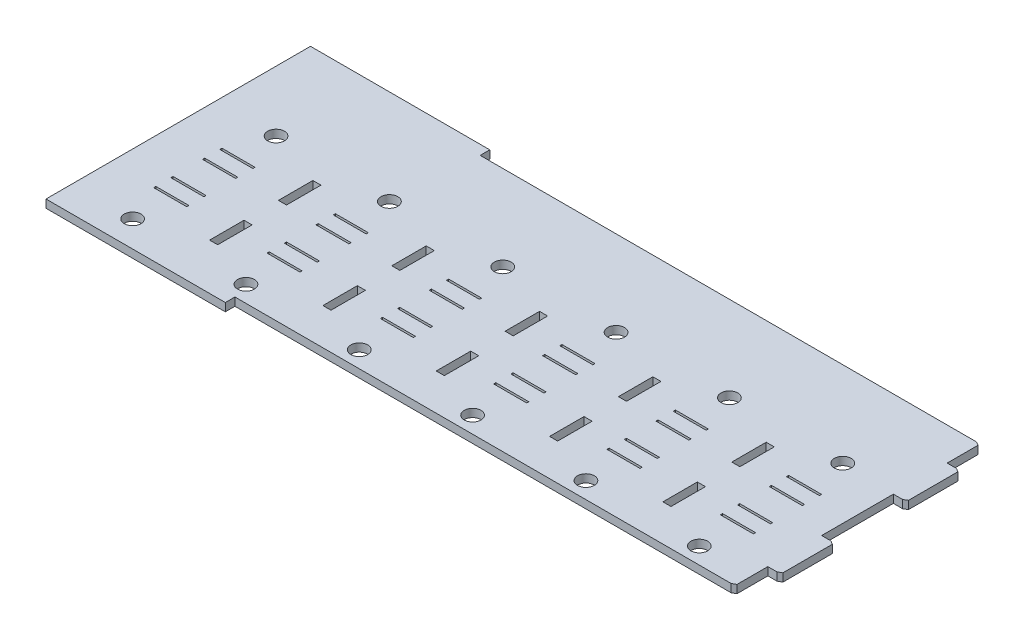
from build123d import *

# Parameters (mm, degrees)
SKETCH1_W             = 245.11
SKETCH1_H             = 93.653112922
BOSS_EXTRUDE1_DEPTH   = 2.8575
CUT_EXTRUDE1_REACH    = 4.857
SKETCH2_W             = 181.61
SKETCH2_H             = 3.399764473
CUT_EXTRUDE3_REACH    = 4.857
SKETCH4_W             = 4.572
SKETCH4_H             = 11.676791988
SKETCH4_H_2           = 25.4
CHAMFER2_SIZE         = 0.762
CHAMFER2_SIZE2        = 1.319822715
CHAMFER2_PART_2_SIZE  = 0.762
CHAMFER2_PART_2_SIZE2 = 1.319822715
CHAMFER2_PART_3_SIZE  = 0.762
CHAMFER2_PART_3_SIZE2 = 1.319822715
CHAMFER3_SIZE         = 0.762
CHAMFER3_SIZE2        = 1.319822715
CHAMFER3_PART_2_SIZE  = 0.762
CHAMFER3_PART_2_SIZE2 = 1.319822715
CHAMFER3_PART_3_SIZE  = 0.762
CHAMFER3_PART_3_SIZE2 = 1.319822715
SKETCH6_W             = 11.684
SKETCH6_H             = 0.762
CUT_EXTRUDE4_DEPTH    = 3.8575
SKETCH9_W             = 2.86258
SKETCH9_H             = 12.192
CUT_EXTRUDE5_DEPTH    = 3.8575
SKETCH11_R            = 2.975
CUT_EXTRUDE6_DEPTH    = 3.8575


with BuildPart() as part:
    # Sketch1 → Boss-Extrude1 (new body)
    with BuildSketch(Plane(origin=(0, 0, 0), x_dir=(1, 0, 0), z_dir=(0, 1, 0))):
        Rectangle(SKETCH1_W, SKETCH1_H)
    extrude(amount=BOSS_EXTRUDE1_DEPTH)

    # Sketch2 → Cut-Extrude1 (cut, up to next)
    with BuildSketch(Plane(origin=(0, 2.8575, 0), x_dir=(1, 0, 0), z_dir=(0, 1, 0)), mode=Mode.PRIVATE) as cut_extrude1_sk1:
        with Locations((31.75, 45.126674225)):
            Rectangle(SKETCH2_W, SKETCH2_H)
    cut_extrude1_tool1 = extrude(cut_extrude1_sk1.sketch, amount=-CUT_EXTRUDE1_REACH, mode=Mode.PRIVATE) & part.part
    add(cut_extrude1_tool1.solids().sort_by_distance((31.75, 2.8575, -45.126674))[0], mode=Mode.SUBTRACT)
    # Sketch2 → Cut-Extrude1 (cut, up to next)
    with BuildSketch(Plane(origin=(0, 2.8575, 0), x_dir=(1, 0, 0), z_dir=(0, 1, 0)), mode=Mode.PRIVATE) as cut_extrude1_sk2:
        with Locations((31.75, -45.126674225)):
            Rectangle(SKETCH2_W, SKETCH2_H)
    cut_extrude1_tool2 = extrude(cut_extrude1_sk2.sketch, amount=-CUT_EXTRUDE1_REACH, mode=Mode.PRIVATE) & part.part
    add(cut_extrude1_tool2.solids().sort_by_distance((31.75, 2.8575, 45.126674))[0], mode=Mode.SUBTRACT)

    # Sketch4 → Cut-Extrude3 (cut, up to next)
    with BuildSketch(Plane(origin=(0, 2.8575, 0), x_dir=(1, 0, 0), z_dir=(0, 1, 0)), mode=Mode.PRIVATE) as cut_extrude3_sk1:
        with Locations((120.269, 37.588395994)):
            Rectangle(SKETCH4_W, SKETCH4_H)
    cut_extrude3_tool1 = extrude(cut_extrude3_sk1.sketch, amount=-CUT_EXTRUDE3_REACH, mode=Mode.PRIVATE) & part.part
    add(cut_extrude3_tool1.solids().sort_by_distance((120.269, 2.8575, -37.588396))[0], mode=Mode.SUBTRACT)
    # Sketch4 → Cut-Extrude3 (cut, up to next)
    with BuildSketch(Plane(origin=(0, 2.8575, 0), x_dir=(1, 0, 0), z_dir=(0, 1, 0)), mode=Mode.PRIVATE) as cut_extrude3_sk2:
        with Locations((120.269, -37.588395994)):
            Rectangle(SKETCH4_W, SKETCH4_H)
    cut_extrude3_tool2 = extrude(cut_extrude3_sk2.sketch, amount=-CUT_EXTRUDE3_REACH, mode=Mode.PRIVATE) & part.part
    add(cut_extrude3_tool2.solids().sort_by_distance((120.269, 2.8575, 37.588396))[0], mode=Mode.SUBTRACT)
    # Sketch4 → Cut-Extrude3 (cut, up to next)
    with BuildSketch(Plane(origin=(0, 2.8575, 0), x_dir=(1, 0, 0), z_dir=(0, 1, 0)), mode=Mode.PRIVATE) as cut_extrude3_sk3:
        with Locations((120.269, 0)):
            Rectangle(SKETCH4_W, SKETCH4_H_2)
    cut_extrude3_tool3 = extrude(cut_extrude3_sk3.sketch, amount=-CUT_EXTRUDE3_REACH, mode=Mode.PRIVATE) & part.part
    add(cut_extrude3_tool3.solids().sort_by_distance((120.269, 2.8575, 0))[0], mode=Mode.SUBTRACT)

    # Chamfer2
    chamfer2_edges = [part.edges().sort_by_distance(p)[0] for p in [
        (122.555, 1.42875, 31.75),
    ]]
    chamfer2_side = [part.faces().sort_by_distance(p)[0] for p in [
        (122.555, 1.42875, 22.225),
    ]]
    chamfer(chamfer2_edges, length=CHAMFER2_SIZE, length2=CHAMFER2_SIZE2, reference=chamfer2_side[0])

    # Chamfer2 part 2
    chamfer2_part_2_edges = [part.edges().sort_by_distance(p)[0] for p in [
        (117.983, 1.42875, 43.426791988),
    ]]
    chamfer2_part_2_side = [part.faces().sort_by_distance(p)[0] for p in [
        (117.983, 1.42875, 37.588395994),
    ]]
    chamfer(chamfer2_part_2_edges, length=CHAMFER2_PART_2_SIZE, length2=CHAMFER2_PART_2_SIZE2, reference=chamfer2_part_2_side[0])

    # Chamfer2 part 3
    chamfer2_part_3_edges = [part.edges().sort_by_distance(p)[0] for p in [
        (122.555, 1.42875, -12.7),
    ]]
    chamfer2_part_3_side = [part.faces().sort_by_distance(p)[0] for p in [
        (122.555, 1.42875, -22.225),
    ]]
    chamfer(chamfer2_part_3_edges, length=CHAMFER2_PART_3_SIZE, length2=CHAMFER2_PART_3_SIZE2, reference=chamfer2_part_3_side[0])

    # Chamfer3
    chamfer3_edges = [part.edges().sort_by_distance(p)[0] for p in [
        (122.555, 1.42875, -31.75),
    ]]
    chamfer3_side = [part.faces().sort_by_distance(p)[0] for p in [
        (122.555, 1.42875, -22.606),
    ]]
    chamfer(chamfer3_edges, length=CHAMFER3_SIZE, length2=CHAMFER3_SIZE2, reference=chamfer3_side[0])

    # Chamfer3 part 2
    chamfer3_part_2_edges = [part.edges().sort_by_distance(p)[0] for p in [
        (117.983, 1.42875, -43.426791988),
    ]]
    chamfer3_part_2_side = [part.faces().sort_by_distance(p)[0] for p in [
        (117.983, 1.42875, -37.588395994),
    ]]
    chamfer(chamfer3_part_2_edges, length=CHAMFER3_PART_2_SIZE, length2=CHAMFER3_PART_2_SIZE2, reference=chamfer3_part_2_side[0])

    # Chamfer3 part 3
    chamfer3_part_3_edges = [part.edges().sort_by_distance(p)[0] for p in [
        (122.555, 1.42875, 12.7),
    ]]
    chamfer3_part_3_side = [part.faces().sort_by_distance(p)[0] for p in [
        (122.555, 1.42875, 21.844),
    ]]
    chamfer(chamfer3_part_3_edges, length=CHAMFER3_PART_3_SIZE, length2=CHAMFER3_PART_3_SIZE2, reference=chamfer3_part_3_side[0])

    # Sketch6 → Cut-Extrude4 (cut, through all)
    with BuildSketch(Plane(origin=(0, 2.8575, 0), x_dir=(1, 0, 0), z_dir=(0, 1, 0))):
        with Locations((99.533234068, -0.475391988)):
            Rectangle(SKETCH6_W, SKETCH6_H)
        with Locations((99.533234068, -6.571391988)):
            Rectangle(SKETCH6_W, SKETCH6_H)
        with Locations((99.533234068, -17.802329902)):
            Rectangle(SKETCH6_W, SKETCH6_H)
        with Locations((99.533234068, -23.898329902)):
            Rectangle(SKETCH6_W, SKETCH6_H)
        with Locations((59.401234068, -0.475391988)):
            Rectangle(SKETCH6_W, SKETCH6_H)
        with Locations((59.401234068, -6.571391988)):
            Rectangle(SKETCH6_W, SKETCH6_H)
        with Locations((59.401234068, -17.802329902)):
            Rectangle(SKETCH6_W, SKETCH6_H)
        with Locations((59.401234068, -23.898329902)):
            Rectangle(SKETCH6_W, SKETCH6_H)
        with Locations((19.269234068, -0.475391988)):
            Rectangle(SKETCH6_W, SKETCH6_H)
        with Locations((19.269234068, -6.571391988)):
            Rectangle(SKETCH6_W, SKETCH6_H)
        with Locations((19.269234068, -17.802329902)):
            Rectangle(SKETCH6_W, SKETCH6_H)
        with Locations((19.269234068, -23.898329902)):
            Rectangle(SKETCH6_W, SKETCH6_H)
        with Locations((-20.862765932, -0.475391988)):
            Rectangle(SKETCH6_W, SKETCH6_H)
        with Locations((-20.862765932, -6.571391988)):
            Rectangle(SKETCH6_W, SKETCH6_H)
        with Locations((-20.862765932, -17.802329902)):
            Rectangle(SKETCH6_W, SKETCH6_H)
        with Locations((-20.862765932, -23.898329902)):
            Rectangle(SKETCH6_W, SKETCH6_H)
        with Locations((-60.994765932, -0.475391988)):
            Rectangle(SKETCH6_W, SKETCH6_H)
        with Locations((-60.994765932, -6.571391988)):
            Rectangle(SKETCH6_W, SKETCH6_H)
        with Locations((-60.994765932, -17.802329902)):
            Rectangle(SKETCH6_W, SKETCH6_H)
        with Locations((-60.994765932, -23.898329902)):
            Rectangle(SKETCH6_W, SKETCH6_H)
        with Locations((-101.126765932, -0.475391988)):
            Rectangle(SKETCH6_W, SKETCH6_H)
        with Locations((-101.126765932, -6.571391988)):
            Rectangle(SKETCH6_W, SKETCH6_H)
        with Locations((-101.126765932, -17.802329902)):
            Rectangle(SKETCH6_W, SKETCH6_H)
        with Locations((-101.126765932, -23.898329902)):
            Rectangle(SKETCH6_W, SKETCH6_H)
    extrude(amount=-CUT_EXTRUDE4_DEPTH, mode=Mode.SUBTRACT)

    # Sketch9 → Cut-Extrude5 (cut, through all)
    with BuildSketch(Plane(origin=(0, 2.8575, 0), x_dir=(1, 0, 0), z_dir=(0, 1, 0))):
        with Locations((80.97711923, 0.007208012)):
            Rectangle(SKETCH9_W, SKETCH9_H)
        with Locations((40.84511923, 0.007208012)):
            Rectangle(SKETCH9_W, SKETCH9_H)
        with Locations((40.84511923, -24.376791988)):
            Rectangle(SKETCH9_W, SKETCH9_H)
        with Locations((0.71311923, 0.007208012)):
            Rectangle(SKETCH9_W, SKETCH9_H)
        with Locations((0.71311923, -24.376791988)):
            Rectangle(SKETCH9_W, SKETCH9_H)
        with Locations((80.97711923, -24.376791988)):
            Rectangle(SKETCH9_W, SKETCH9_H)
        with Locations((-39.41888077, 0.007208012)):
            Rectangle(SKETCH9_W, SKETCH9_H)
        with Locations((-39.41888077, -24.376791988)):
            Rectangle(SKETCH9_W, SKETCH9_H)
        with Locations((-79.55088077, 0.007208012)):
            Rectangle(SKETCH9_W, SKETCH9_H)
        with Locations((-79.55088077, -24.376791988)):
            Rectangle(SKETCH9_W, SKETCH9_H)
    extrude(amount=-CUT_EXTRUDE5_DEPTH, mode=Mode.SUBTRACT)

    # Sketch11 → Cut-Extrude6 (cut, through all)
    with BuildSketch(Plane(origin=(0, 2.8575, 0), x_dir=(1, 0, 0), z_dir=(0, 1, 0))):
        with Locations((99.533234068, 13.215208012)):
            Circle(SKETCH11_R)
        with Locations((99.533234068, -37.584791988)):
            Circle(SKETCH11_R)
        with Locations((59.401234068, -37.584791988)):
            Circle(SKETCH11_R)
        with Locations((59.401234068, 13.215208012)):
            Circle(SKETCH11_R)
        with Locations((19.269234068, -37.584791988)):
            Circle(SKETCH11_R)
        with Locations((19.269234068, 13.215208012)):
            Circle(SKETCH11_R)
        with Locations((-20.862765932, -37.584791988)):
            Circle(SKETCH11_R)
        with Locations((-20.862765932, 13.215208012)):
            Circle(SKETCH11_R)
        with Locations((-60.994765932, -37.584791988)):
            Circle(SKETCH11_R)
        with Locations((-60.994765932, 13.215208012)):
            Circle(SKETCH11_R)
        with Locations((-101.126765932, -37.584791988)):
            Circle(SKETCH11_R)
        with Locations((-101.126765932, 13.215208012)):
            Circle(SKETCH11_R)
    extrude(amount=-CUT_EXTRUDE6_DEPTH, mode=Mode.SUBTRACT)


solid = part.part
